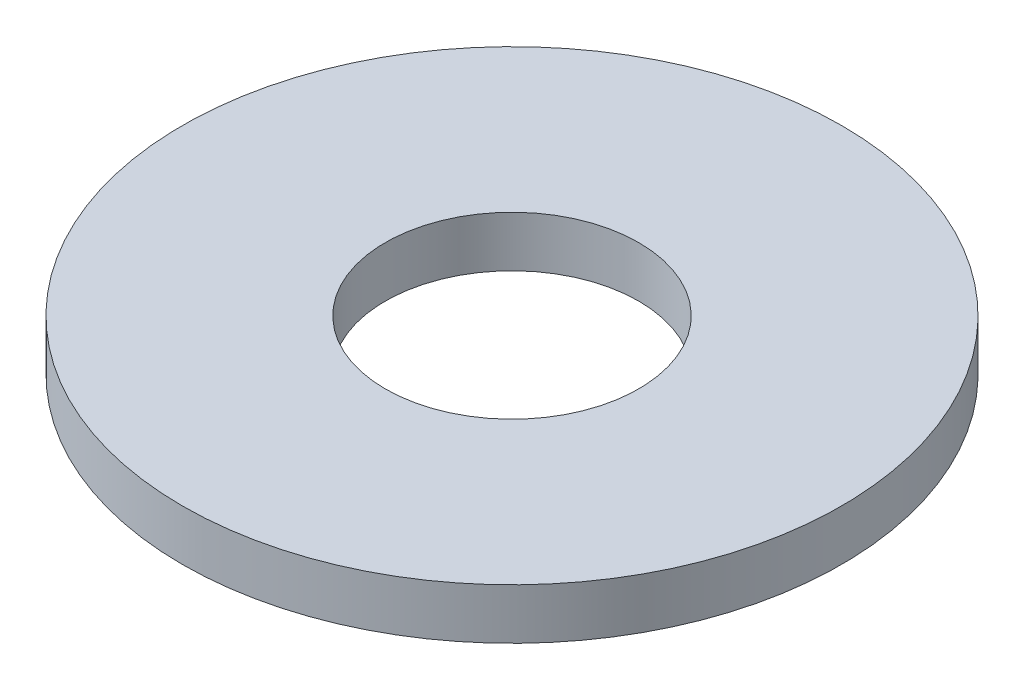
from build123d import *

# Parameters (mm, degrees)
SKETCH1_R           = 6.5
SKETCH1_R_2         = 2.5
BOSS_EXTRUDE1_DEPTH = 1


with BuildPart() as part:
    # Sketch1 → Boss-Extrude1 (new body)
    with BuildSketch(Plane(origin=(0, 0, 0), x_dir=(1, 0, 0), z_dir=(0, 1, 0))):
        Circle(SKETCH1_R)
        Polygon((-2.742413779, -4.75), (2.742413779, -4.75), (5.484827557, 0), (2.742413779, 4.75), (-2.742413779, 4.75), (-5.484827557, 0), align=None, mode=Mode.SUBTRACT)
        Polygon((-5.484827557, 0), (-2.742413779, -4.75), (2.742413779, -4.75), (5.484827557, 0), (2.742413779, 4.75), (-2.742413779, 4.75), align=None)
        Circle(SKETCH1_R_2, mode=Mode.SUBTRACT)
    extrude(amount=-BOSS_EXTRUDE1_DEPTH)


solid = part.part
